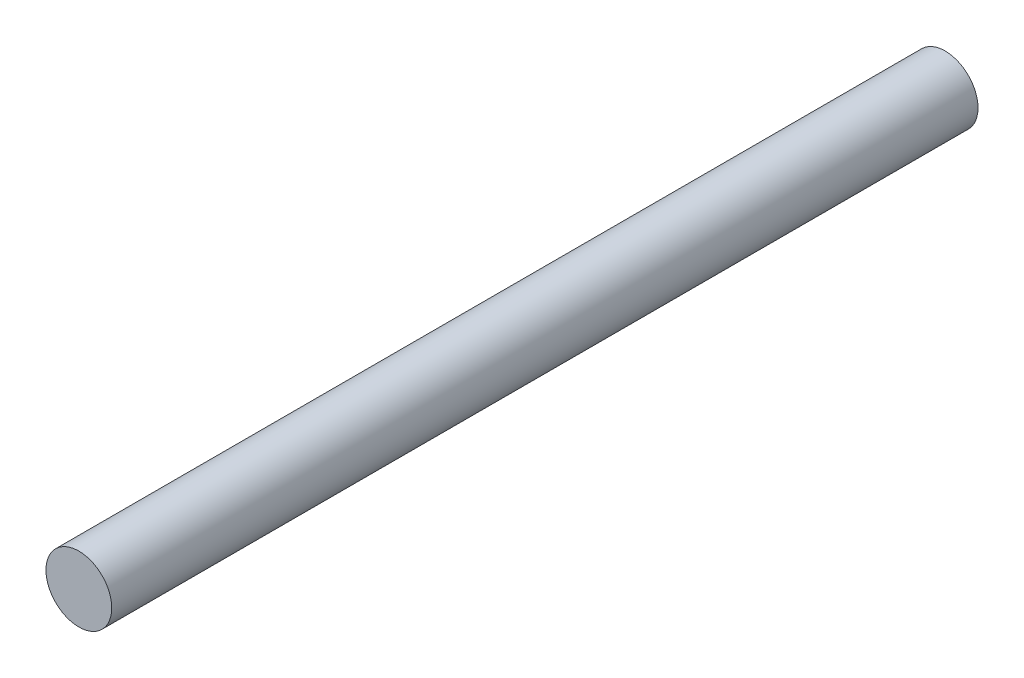
from build123d import *

# Parameters (mm, degrees)
ESBO_O1_R                = 6
RESSALTO_EXTRUS_O1_DEPTH = 158


with BuildPart() as part:
    # Esboço1 → Ressalto-extrusão1 (new body)
    with BuildSketch(Plane.XY):
        Circle(ESBO_O1_R)
    extrude(amount=RESSALTO_EXTRUS_O1_DEPTH)


solid = part.part
